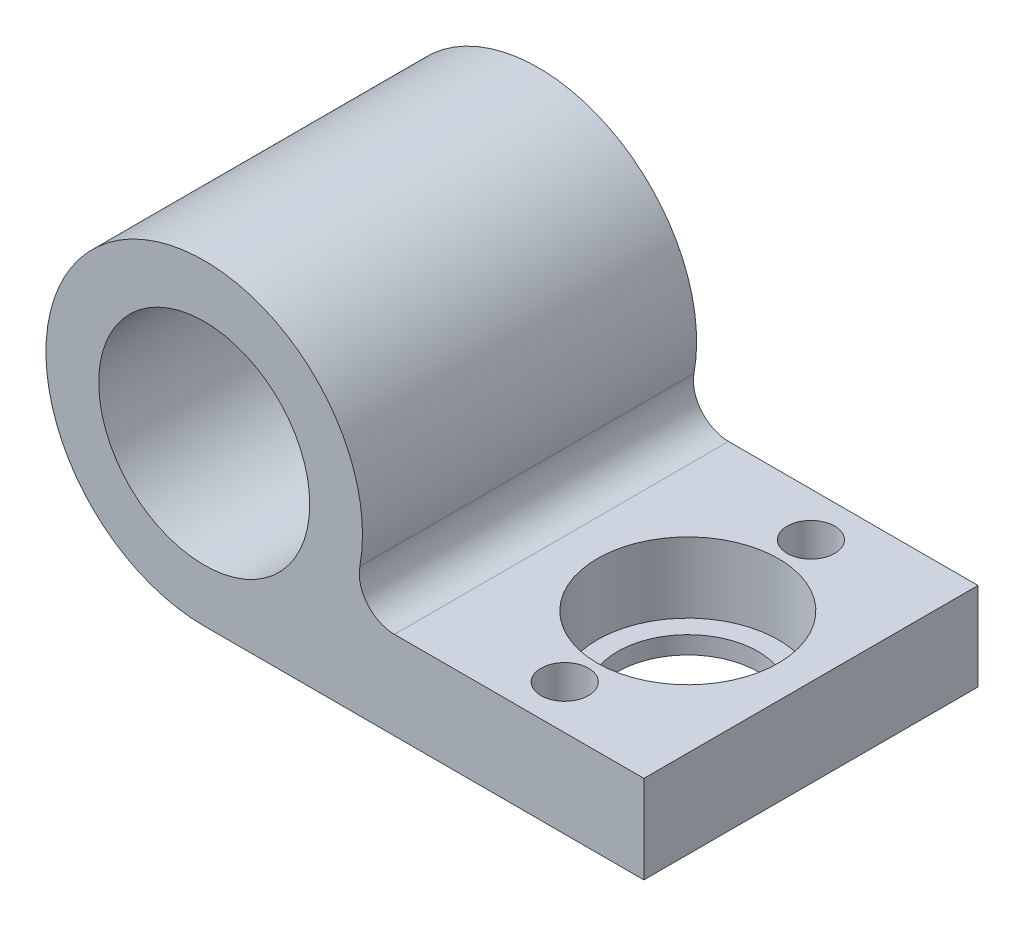
from build123d import *

# Parameters (mm, degrees)
SKETCH1_R                  = 9
SKETCH1_R_2                = 6
MAIN_DEPTH                 = 9.5
SKETCH2_W                  = 25
SKETCH2_H                  = 19
SKETCH2_R                  = 4
SKETCH2_R_2                = 1.35
BALLSUPPORTEXTRUSION_DEPTH = 5
SKETCH3_R                  = 5.15
BALLSUPPORTHOLE_DEPTH      = 4
FILLET2_R                  = 2
SKETCH5_R                  = 6
CUT_EXTRUDE2_DEPTH         = 20


with BuildPart() as part:
    # Sketch1 → Main (new body, symmetric)
    with BuildSketch(Plane.XY):
        Circle(SKETCH1_R)
        Circle(SKETCH1_R_2, mode=Mode.SUBTRACT)
    extrude(amount=MAIN_DEPTH, both=True)

    # Sketch2 → BallSupportExtrusion (add)
    with BuildSketch(Plane(origin=(0, -9, 0), x_dir=(1, 0, 0), z_dir=(0, 1, 0))):
        with Locations((12.5, 0)):
            Rectangle(SKETCH2_W, SKETCH2_H)
        with Locations((18, 0)):
            Circle(SKETCH2_R, mode=Mode.SUBTRACT)
        with Locations((18, 7)):
            Circle(SKETCH2_R_2, mode=Mode.SUBTRACT)
        with Locations((18, -7)):
            Circle(SKETCH2_R_2, mode=Mode.SUBTRACT)
    extrude(amount=BALLSUPPORTEXTRUSION_DEPTH)

    # Sketch3 → BallSupportHole (cut)
    with BuildSketch(Plane(origin=(0, -4, 0), x_dir=(1, 0, 0), z_dir=(0, 1, 0))):
        with Locations((18, 0)):
            Circle(SKETCH3_R)
    extrude(amount=-BALLSUPPORTHOLE_DEPTH, mode=Mode.SUBTRACT)

    # Fillet2
    fillet2_edges = [part.edges().sort_by_distance(p)[0] for p in [
        (8.062257748, -4, 0),
    ]]
    fillet(fillet2_edges, radius=FILLET2_R)

    # Sketch5 → Cut-Extrude2 (cut, through all)
    with BuildSketch(Plane.XY.offset(9.5)):
        Circle(SKETCH5_R)
    extrude(amount=-CUT_EXTRUDE2_DEPTH, mode=Mode.SUBTRACT)


solid = part.part
